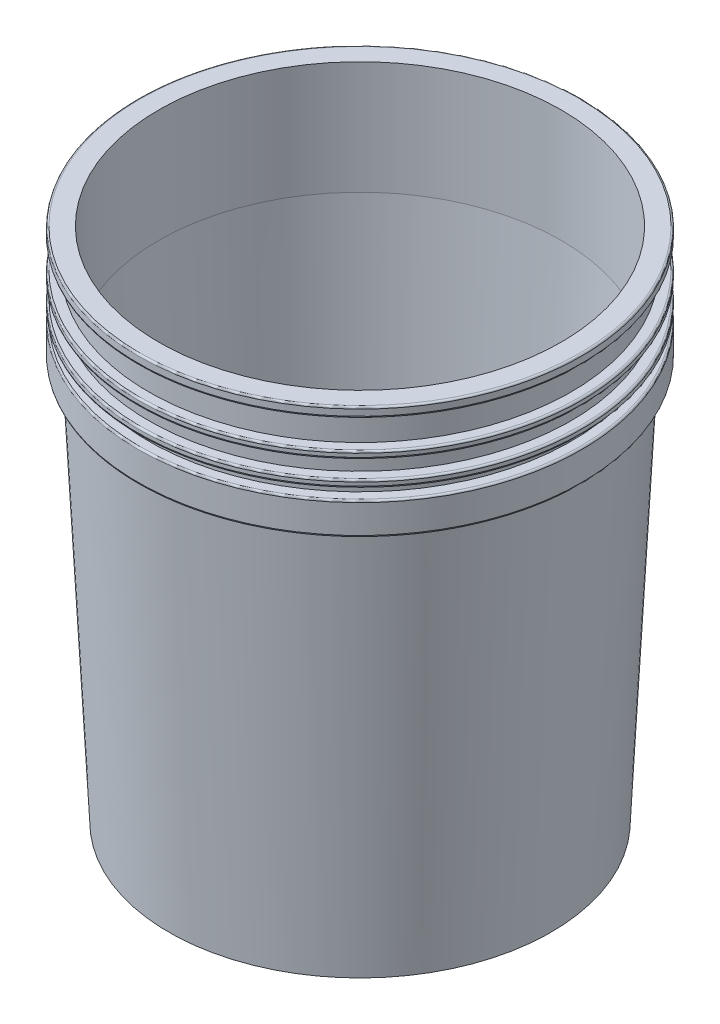
from build123d import *

# Parameters (mm, degrees)
FILLET1_R = 1.27


with BuildPart() as part:
    # Sketch1 → Revolve1 (revolve)
    with BuildSketch(Plane.XY):
        Polygon((0, 6.35), (25.4, 6.35), (25.4, 0), (32.4, 0), (32.4, 6.35), (129.664353063, 6.35), (129.3495, 0), (136.3495, 0), (150.6116, 287.64), (158.2316, 287.64), (158.2316, 310.5), (150.6116, 310.5), (150.6116, 318.12), (158.2316, 318.12), (158.2316, 323.2), (150.6116, 323.2), (150.6116, 335.9), (158.2316, 335.9), (158.2316, 340.98), (150.6116, 340.98), (150.6116, 361.3), (158.2316, 361.3), (158.2316, 368.3), (143.6116, 368.3), (143.6116, 287.64), (130.011435179, 13.35), (0, 13.35), align=None)
    revolve(axis=Axis((0, 0, 0), (0, 1, 0)))

    # Fillet1
    fillet1_edges = [part.edges().sort_by_distance(p)[0] for p in [
        (-158.2316, 368.3, 0),
        (-158.2316, 361.3, 0),
        (-158.2316, 340.98, 0),
        (-158.2316, 335.9, 0),
        (-158.2316, 323.2, 0),
        (-158.2316, 318.12, 0),
        (-158.2316, 310.5, 0),
        (-158.2316, 287.64, 0),
    ]]
    fillet(fillet1_edges, radius=FILLET1_R)


solid = part.part
